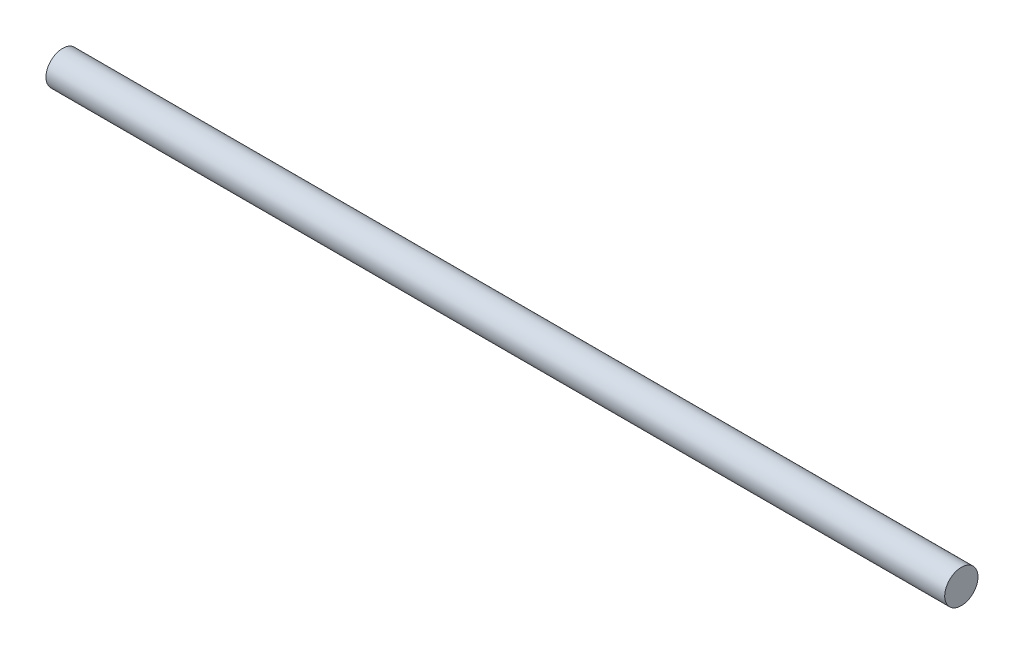
from build123d import *

# Parameters (mm, degrees)
SKETCH1_R           = 6.35
BOSS_EXTRUDE1_DEPTH = 171.45


with BuildPart() as part:
    # Sketch1 → Boss-Extrude1 (new body, symmetric)
    with BuildSketch(Plane(origin=(0, 0, 0), x_dir=(0, 0, -1), z_dir=(1, 0, 0))):
        Circle(SKETCH1_R)
    extrude(amount=BOSS_EXTRUDE1_DEPTH, both=True)


solid = part.part
